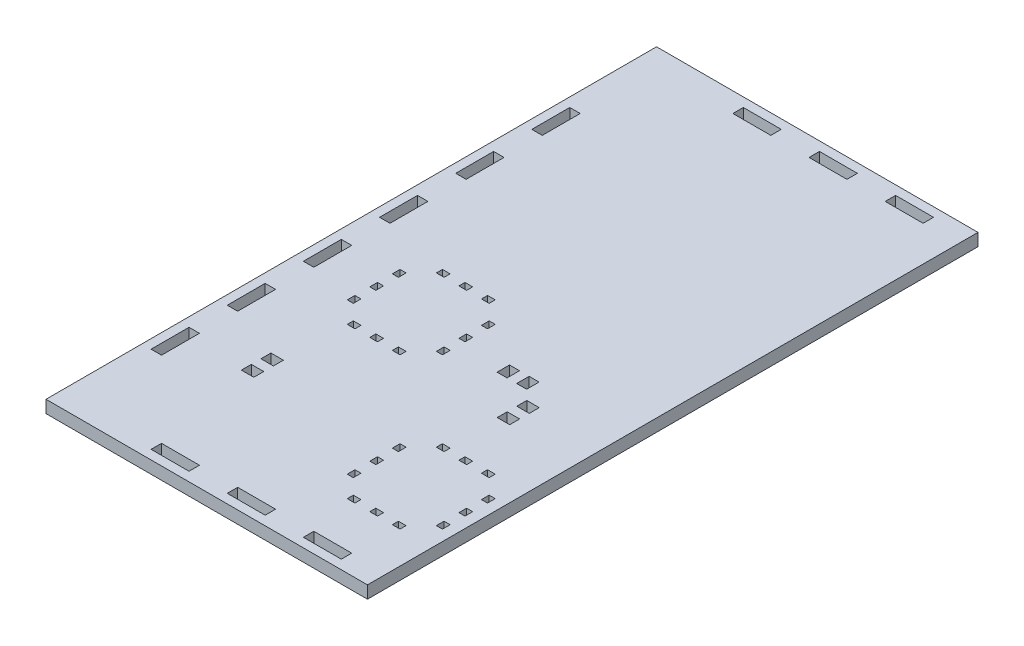
from build123d import *

# Parameters (mm, degrees)
SKETCH1_W           = 311.4
SKETCH1_H           = 311.4
SKETCH1_W_2         = 5.4
SKETCH1_H_2         = 19.425
SKETCH1_W_3         = 19.425
SKETCH1_H_3         = 5.4
SKETCH1_W_4         = 4.000000243
SKETCH1_H_4         = 3.174999693
SKETCH1_W_5         = 3.175000307
SKETCH1_H_5         = 3.999999757
SKETCH1_H_6         = 3.999999756
SKETCH1_W_6         = 4
SKETCH1_H_7         = 3.175
SKETCH1_W_7         = 3.175
SKETCH1_H_8         = 4
SKETCH1_W_8         = 3.174999693
SKETCH1_H_9         = 4.000000243
SKETCH1_H_10        = 4.000000244
BOSS_EXTRUDE4_DEPTH = 6.35
SKETCH4_W           = 19.425
SKETCH4_H           = 5.4
SKETCH4_W_2         = 5.4
SKETCH4_H_2         = 19.425
CUT_EXTRUDE3_DEPTH  = 6.35
SKETCH5_W           = 311.48128
SKETCH5_H           = 311.48128
SKETCH5_W_2         = 19.34372
SKETCH5_H_2         = 5.31872
SKETCH5_W_3         = 5.31872
SKETCH5_H_3         = 19.34372
SKETCH5_W_4         = 3.918720243
SKETCH5_H_4         = 3.093719693
SKETCH5_W_5         = 3.09372
SKETCH5_H_5         = 3.91872
SKETCH5_W_6         = 3.91872
SKETCH5_H_6         = 3.09372
SKETCH5_W_7         = 3.093720307
SKETCH5_H_7         = 3.918719757
SKETCH5_H_8         = 3.918719756
SKETCH5_W_8         = 3.093719693
SKETCH5_H_9         = 3.918720243
SKETCH5_H_10        = 3.918720244
BOSS_EXTRUDE5_DEPTH = 6.35
SKETCH7_W           = 6.35
SKETCH7_H           = 5.081279906
SKETCH7_W_2         = 5.081279906
SKETCH7_H_2         = 6.35
CUT_EXTRUDE4_DEPTH  = 6.35
SKETCH8_W           = 147.48128
SKETCH8_H           = 311.48128
CUT_EXTRUDE5_DEPTH  = 6.35


with BuildPart() as part:
    # Sketch1 → Boss-Extrude4 (new body)
    with BuildSketch(Plane(origin=(0, 0, 0), x_dir=(1, 0, 0), z_dir=(0, 1, 0))):
        with Locations((148.1875, 148.2125)):
            Rectangle(SKETCH1_W, SKETCH1_H)
        with Locations((-0.2125, 51.075)):
            Rectangle(SKETCH1_W_2, SKETCH1_H_2, mode=Mode.SUBTRACT)
        with Locations((-0.2125, 89.925)):
            Rectangle(SKETCH1_W_2, SKETCH1_H_2, mode=Mode.SUBTRACT)
        with Locations((-0.2125, 128.775)):
            Rectangle(SKETCH1_W_2, SKETCH1_H_2, mode=Mode.SUBTRACT)
        with Locations((-0.2125, 167.625)):
            Rectangle(SKETCH1_W_2, SKETCH1_H_2, mode=Mode.SUBTRACT)
        with Locations((-0.2125, 206.475)):
            Rectangle(SKETCH1_W_2, SKETCH1_H_2, mode=Mode.SUBTRACT)
        with Locations((-0.2125, 245.325)):
            Rectangle(SKETCH1_W_2, SKETCH1_H_2, mode=Mode.SUBTRACT)
        with Locations((51.075, 296.6125)):
            Rectangle(SKETCH1_W_3, SKETCH1_H_3, mode=Mode.SUBTRACT)
        with Locations((89.925, 296.6125)):
            Rectangle(SKETCH1_W_3, SKETCH1_H_3, mode=Mode.SUBTRACT)
        with Locations((128.775, 296.6125)):
            Rectangle(SKETCH1_W_3, SKETCH1_H_3, mode=Mode.SUBTRACT)
        with Locations((167.625, 296.6125)):
            Rectangle(SKETCH1_W_3, SKETCH1_H_3, mode=Mode.SUBTRACT)
        with Locations((206.475, 296.6125)):
            Rectangle(SKETCH1_W_3, SKETCH1_H_3, mode=Mode.SUBTRACT)
        with Locations((245.325, 296.6125)):
            Rectangle(SKETCH1_W_3, SKETCH1_H_3, mode=Mode.SUBTRACT)
        with Locations((296.5875, 245.35)):
            Rectangle(SKETCH1_W_2, SKETCH1_H_2, mode=Mode.SUBTRACT)
        with Locations((296.5875, 206.5)):
            Rectangle(SKETCH1_W_2, SKETCH1_H_2, mode=Mode.SUBTRACT)
        with Locations((296.5875, 167.65)):
            Rectangle(SKETCH1_W_2, SKETCH1_H_2, mode=Mode.SUBTRACT)
        with Locations((296.5875, 128.8)):
            Rectangle(SKETCH1_W_2, SKETCH1_H_2, mode=Mode.SUBTRACT)
        with Locations((296.5875, 89.95)):
            Rectangle(SKETCH1_W_2, SKETCH1_H_2, mode=Mode.SUBTRACT)
        with Locations((296.5875, 51.1)):
            Rectangle(SKETCH1_W_2, SKETCH1_H_2, mode=Mode.SUBTRACT)
        with Locations((245.3, -0.1875)):
            Rectangle(SKETCH1_W_3, SKETCH1_H_3, mode=Mode.SUBTRACT)
        with Locations((206.45, -0.1875)):
            Rectangle(SKETCH1_W_3, SKETCH1_H_3, mode=Mode.SUBTRACT)
        with Locations((167.6, -0.1875)):
            Rectangle(SKETCH1_W_3, SKETCH1_H_3, mode=Mode.SUBTRACT)
        with Locations((128.75, -0.1875)):
            Rectangle(SKETCH1_W_3, SKETCH1_H_3, mode=Mode.SUBTRACT)
        with Locations((89.9, -0.1875)):
            Rectangle(SKETCH1_W_3, SKETCH1_H_3, mode=Mode.SUBTRACT)
        with Locations((51.05, -0.1875)):
            Rectangle(SKETCH1_W_3, SKETCH1_H_3, mode=Mode.SUBTRACT)
        with Locations((38.162499879, 149.42500074)):
            Rectangle(SKETCH1_W_4, SKETCH1_H_4, mode=Mode.SUBTRACT)
        with Locations((49.662499879, 149.42500074)):
            Rectangle(SKETCH1_W_4, SKETCH1_H_4, mode=Mode.SUBTRACT)
        with Locations((61.162499879, 149.42500074)):
            Rectangle(SKETCH1_W_4, SKETCH1_H_4, mode=Mode.SUBTRACT)
        with Locations((72.40000236, 138.187501742)):
            Rectangle(SKETCH1_W_5, SKETCH1_H_5, mode=Mode.SUBTRACT)
        with Locations((72.40000236, 126.68750181)):
            Rectangle(SKETCH1_W_5, SKETCH1_H_5, mode=Mode.SUBTRACT)
        with Locations((72.40000236, 115.187501877)):
            Rectangle(SKETCH1_W_5, SKETCH1_H_6, mode=Mode.SUBTRACT)
        with Locations((61.162501621, 103.95)):
            Rectangle(SKETCH1_W_6, SKETCH1_H_7, mode=Mode.SUBTRACT)
        with Locations((49.662501621, 103.95)):
            Rectangle(SKETCH1_W_6, SKETCH1_H_7, mode=Mode.SUBTRACT)
        with Locations((38.162501621, 103.95)):
            Rectangle(SKETCH1_W_6, SKETCH1_H_7, mode=Mode.SUBTRACT)
        with Locations((26.925001621, 115.1875)):
            Rectangle(SKETCH1_W_7, SKETCH1_H_8, mode=Mode.SUBTRACT)
        with Locations((26.925001621, 126.6875)):
            Rectangle(SKETCH1_W_7, SKETCH1_H_8, mode=Mode.SUBTRACT)
        with Locations((26.925001621, 138.1875)):
            Rectangle(SKETCH1_W_7, SKETCH1_H_8, mode=Mode.SUBTRACT)
        with Locations((115.162499879, 72.42500074)):
            Rectangle(SKETCH1_W_4, SKETCH1_H_4, mode=Mode.SUBTRACT)
        with Locations((126.662499879, 72.42500074)):
            Rectangle(SKETCH1_W_4, SKETCH1_H_4, mode=Mode.SUBTRACT)
        with Locations((138.162499879, 72.42500074)):
            Rectangle(SKETCH1_W_4, SKETCH1_H_4, mode=Mode.SUBTRACT)
        with Locations((149.400002361, 61.187501743)):
            Rectangle(SKETCH1_W_8, SKETCH1_H_9, mode=Mode.SUBTRACT)
        with Locations((149.400002361, 49.68750181)):
            Rectangle(SKETCH1_W_8, SKETCH1_H_9, mode=Mode.SUBTRACT)
        with Locations((149.400002361, 38.187501877)):
            Rectangle(SKETCH1_W_8, SKETCH1_H_10, mode=Mode.SUBTRACT)
        with Locations((138.162501621, 26.95)):
            Rectangle(SKETCH1_W_6, SKETCH1_H_7, mode=Mode.SUBTRACT)
        with Locations((126.662501621, 26.95)):
            Rectangle(SKETCH1_W_6, SKETCH1_H_7, mode=Mode.SUBTRACT)
        with Locations((115.162501621, 26.95)):
            Rectangle(SKETCH1_W_6, SKETCH1_H_7, mode=Mode.SUBTRACT)
        with Locations((103.925001621, 38.1875)):
            Rectangle(SKETCH1_W_7, SKETCH1_H_8, mode=Mode.SUBTRACT)
        with Locations((103.925001621, 49.6875)):
            Rectangle(SKETCH1_W_7, SKETCH1_H_8, mode=Mode.SUBTRACT)
        with Locations((103.925001621, 61.1875)):
            Rectangle(SKETCH1_W_7, SKETCH1_H_8, mode=Mode.SUBTRACT)
    extrude(amount=BOSS_EXTRUDE4_DEPTH)

    # Sketch4 → Cut-Extrude3 (cut)
    with BuildSketch(Plane(origin=(0, 6.35, 0), x_dir=(1, 0, 0), z_dir=(0, 1, 0))):
        with Locations((12.225, 296.6125)):
            Rectangle(SKETCH4_W, SKETCH4_H)
        with Locations((-0.2125, 284.175)):
            Rectangle(SKETCH4_W_2, SKETCH4_H_2)
        with BuildLine():
            ThreePointArc((2.512500017, 299.287442129), (-1.322027524, 297.714705253), (-2.9125, 293.8875))
            Line((-2.9125, 293.8875), (2.4875, 293.8875))
            Line((2.4875, 293.8875), (2.5125, 293.9125))
            Line((2.5125, 293.9125), (2.5125, 299.287442129))
        make_face()
        with BuildLine():
            Line((293.8875, 293.9125), (299.2875, 293.9125))
            ThreePointArc((299.2875, 293.9125), (297.705876618, 297.730876618), (293.8875, 299.3125))
            Line((293.8875, 299.3125), (293.8875, 293.9125))
        make_face()
        with Locations((284.175, 296.6125)):
            Rectangle(SKETCH4_W, SKETCH4_H)
        with Locations((296.5875, 284.2)):
            Rectangle(SKETCH4_W_2, SKETCH4_H_2)
        with Locations((-0.2125, 12.225)):
            Rectangle(SKETCH4_W_2, SKETCH4_H_2)
        with Locations((12.2, -0.1875)):
            Rectangle(SKETCH4_W, SKETCH4_H)
        with BuildLine():
            ThreePointArc((2.4875, -2.8875), (-1.330876618, -1.305876618), (-2.9125, 2.5125))
            Line((-2.9125, 2.5125), (2.4875, 2.5125))
            Line((2.4875, 2.5125), (2.4875, -2.8875))
        make_face()
        with BuildLine():
            Line((293.8875, 2.5375), (293.8625, 2.5125))
            Line((293.8625, 2.5125), (293.8625, -2.8875))
            ThreePointArc((293.8625, -2.8875), (297.689705247, -1.29702753), (299.262442129, 2.5375))
            Line((299.262442129, 2.5375), (293.8875, 2.5375))
        make_face()
        with Locations((284.15, -0.1875)):
            Rectangle(SKETCH4_W, SKETCH4_H)
        with Locations((296.5875, 12.25)):
            Rectangle(SKETCH4_W_2, SKETCH4_H_2)
    extrude(amount=-CUT_EXTRUDE3_DEPTH, mode=Mode.SUBTRACT)

    # Sketch5 → Boss-Extrude5 (add)
    with BuildSketch(Plane(origin=(0, 6.35, 0), x_dir=(1, 0, 0), z_dir=(0, 1, 0))):
        with Locations((148.1875, 148.2125)):
            Rectangle(SKETCH5_W, SKETCH5_H)
        with Locations((245.325, 296.6125)):
            Rectangle(SKETCH5_W_2, SKETCH5_H_2, mode=Mode.SUBTRACT)
        with Locations((296.5875, 206.5)):
            Rectangle(SKETCH5_W_3, SKETCH5_H_3, mode=Mode.SUBTRACT)
        with Locations((296.5875, 51.1)):
            Rectangle(SKETCH5_W_3, SKETCH5_H_3, mode=Mode.SUBTRACT)
        with Locations((296.5875, 245.35)):
            Rectangle(SKETCH5_W_3, SKETCH5_H_3, mode=Mode.SUBTRACT)
        with Locations((296.5875, 167.65)):
            Rectangle(SKETCH5_W_3, SKETCH5_H_3, mode=Mode.SUBTRACT)
        with Locations((51.075, 296.6125)):
            Rectangle(SKETCH5_W_2, SKETCH5_H_2, mode=Mode.SUBTRACT)
        with Locations((296.5875, 128.8)):
            Rectangle(SKETCH5_W_3, SKETCH5_H_3, mode=Mode.SUBTRACT)
        with Locations((245.3, -0.1875)):
            Rectangle(SKETCH5_W_2, SKETCH5_H_2, mode=Mode.SUBTRACT)
        with Locations((206.45, -0.1875)):
            Rectangle(SKETCH5_W_2, SKETCH5_H_2, mode=Mode.SUBTRACT)
        with Locations((89.925, 296.6125)):
            Rectangle(SKETCH5_W_2, SKETCH5_H_2, mode=Mode.SUBTRACT)
        with Locations((296.5875, 89.95)):
            Rectangle(SKETCH5_W_3, SKETCH5_H_3, mode=Mode.SUBTRACT)
        with Locations((128.775, 296.6125)):
            Rectangle(SKETCH5_W_2, SKETCH5_H_2, mode=Mode.SUBTRACT)
        with Locations((-0.2125, 167.625)):
            Rectangle(SKETCH5_W_3, SKETCH5_H_3, mode=Mode.SUBTRACT)
        with Locations((167.625, 296.6125)):
            Rectangle(SKETCH5_W_2, SKETCH5_H_2, mode=Mode.SUBTRACT)
        with Locations((167.6, -0.1875)):
            Rectangle(SKETCH5_W_2, SKETCH5_H_2, mode=Mode.SUBTRACT)
        with Locations((206.475, 296.6125)):
            Rectangle(SKETCH5_W_2, SKETCH5_H_2, mode=Mode.SUBTRACT)
        with Locations((-0.2125, 245.325)):
            Rectangle(SKETCH5_W_3, SKETCH5_H_3, mode=Mode.SUBTRACT)
        with Locations((128.75, -0.1875)):
            Rectangle(SKETCH5_W_2, SKETCH5_H_2, mode=Mode.SUBTRACT)
        with Locations((-0.2125, 206.475)):
            Rectangle(SKETCH5_W_3, SKETCH5_H_3, mode=Mode.SUBTRACT)
        with Locations((49.662499879, 149.42500074)):
            Rectangle(SKETCH5_W_4, SKETCH5_H_4, mode=Mode.SUBTRACT)
        with Locations((89.9, -0.1875)):
            Rectangle(SKETCH5_W_2, SKETCH5_H_2, mode=Mode.SUBTRACT)
        with Locations((61.162499879, 149.42500074)):
            Rectangle(SKETCH5_W_4, SKETCH5_H_4, mode=Mode.SUBTRACT)
        with Locations((51.05, -0.1875)):
            Rectangle(SKETCH5_W_2, SKETCH5_H_2, mode=Mode.SUBTRACT)
        with Locations((38.162499879, 149.42500074)):
            Rectangle(SKETCH5_W_4, SKETCH5_H_4, mode=Mode.SUBTRACT)
        with Locations((-0.2125, 51.075)):
            Rectangle(SKETCH5_W_3, SKETCH5_H_3, mode=Mode.SUBTRACT)
        with Locations((-0.2125, 89.925)):
            Rectangle(SKETCH5_W_3, SKETCH5_H_3, mode=Mode.SUBTRACT)
        with Locations((26.925001621, 138.1875)):
            Rectangle(SKETCH5_W_5, SKETCH5_H_5, mode=Mode.SUBTRACT)
        with Locations((-0.2125, 128.775)):
            Rectangle(SKETCH5_W_3, SKETCH5_H_3, mode=Mode.SUBTRACT)
        with Locations((26.925001621, 126.6875)):
            Rectangle(SKETCH5_W_5, SKETCH5_H_5, mode=Mode.SUBTRACT)
        with Locations((26.925001621, 115.1875)):
            Rectangle(SKETCH5_W_5, SKETCH5_H_5, mode=Mode.SUBTRACT)
        with Locations((38.162501621, 103.95)):
            Rectangle(SKETCH5_W_6, SKETCH5_H_6, mode=Mode.SUBTRACT)
        with Locations((49.662501621, 103.95)):
            Rectangle(SKETCH5_W_6, SKETCH5_H_6, mode=Mode.SUBTRACT)
        with Locations((61.162501621, 103.95)):
            Rectangle(SKETCH5_W_6, SKETCH5_H_6, mode=Mode.SUBTRACT)
        with Locations((72.40000236, 138.187501742)):
            Rectangle(SKETCH5_W_7, SKETCH5_H_7, mode=Mode.SUBTRACT)
        with Locations((72.40000236, 126.68750181)):
            Rectangle(SKETCH5_W_7, SKETCH5_H_7, mode=Mode.SUBTRACT)
        with Locations((72.40000236, 115.187501877)):
            Rectangle(SKETCH5_W_7, SKETCH5_H_8, mode=Mode.SUBTRACT)
        with Locations((126.662499879, 72.42500074)):
            Rectangle(SKETCH5_W_4, SKETCH5_H_4, mode=Mode.SUBTRACT)
        with Locations((115.162499879, 72.42500074)):
            Rectangle(SKETCH5_W_4, SKETCH5_H_4, mode=Mode.SUBTRACT)
        with Locations((138.162499879, 72.42500074)):
            Rectangle(SKETCH5_W_4, SKETCH5_H_4, mode=Mode.SUBTRACT)
        with Locations((149.400002361, 61.187501743)):
            Rectangle(SKETCH5_W_8, SKETCH5_H_9, mode=Mode.SUBTRACT)
        with Locations((149.400002361, 49.68750181)):
            Rectangle(SKETCH5_W_8, SKETCH5_H_9, mode=Mode.SUBTRACT)
        with Locations((149.400002361, 38.187501877)):
            Rectangle(SKETCH5_W_8, SKETCH5_H_10, mode=Mode.SUBTRACT)
        with Locations((138.162501621, 26.95)):
            Rectangle(SKETCH5_W_6, SKETCH5_H_6, mode=Mode.SUBTRACT)
        with Locations((126.662501621, 26.95)):
            Rectangle(SKETCH5_W_6, SKETCH5_H_6, mode=Mode.SUBTRACT)
        with Locations((115.162501621, 26.95)):
            Rectangle(SKETCH5_W_6, SKETCH5_H_6, mode=Mode.SUBTRACT)
        with Locations((103.925001621, 38.1875)):
            Rectangle(SKETCH5_W_5, SKETCH5_H_5, mode=Mode.SUBTRACT)
        with Locations((103.925001621, 49.6875)):
            Rectangle(SKETCH5_W_5, SKETCH5_H_5, mode=Mode.SUBTRACT)
        with Locations((103.925001621, 61.1875)):
            Rectangle(SKETCH5_W_5, SKETCH5_H_5, mode=Mode.SUBTRACT)
    extrude(amount=-BOSS_EXTRUDE5_DEPTH)

    # Sketch7 → Cut-Extrude4 (cut)
    with BuildSketch(Plane.XZ):
        with Locations((32.56878001, -57.739466447)):
            Rectangle(SKETCH7_W, SKETCH7_H)
        with Locations((32.56878001, -67.739466353)):
            Rectangle(SKETCH7_W, SKETCH7_H)
        with Locations((118.796859812, -102.046446074)):
            Rectangle(SKETCH7_W, SKETCH7_H)
        with Locations((118.796859812, -112.04644598)):
            Rectangle(SKETCH7_W, SKETCH7_H)
        with Locations((108.081219859, -122.680805933)):
            Rectangle(SKETCH7_W_2, SKETCH7_H_2)
        with Locations((98.081219953, -122.680805933)):
            Rectangle(SKETCH7_W_2, SKETCH7_H_2)
    extrude(amount=-CUT_EXTRUDE4_DEPTH, mode=Mode.SUBTRACT)

    # Sketch8 → Cut-Extrude5 (cut)
    with BuildSketch(Plane.XZ):
        with Locations((230.1875, -148.2125)):
            Rectangle(SKETCH8_W, SKETCH8_H)
    extrude(amount=-CUT_EXTRUDE5_DEPTH, mode=Mode.SUBTRACT)


solid = part.part
